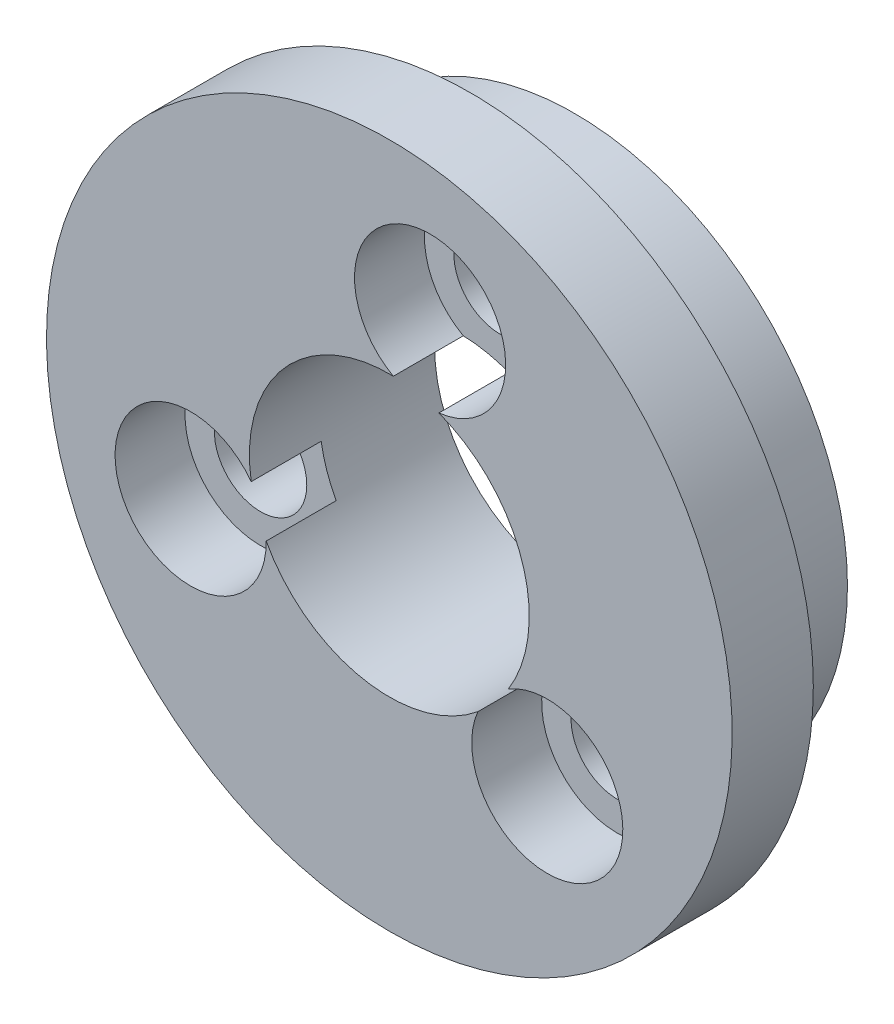
from build123d import *

# Parameters (mm, degrees)
SKETCH1_R           = 12.25
BOSS_EXTRUDE1_DEPTH = 2.9
CUT_EXTRUDE1_REACH  = 364.631
SKETCH2_R           = 5
CUT_EXTRUDE2_REACH  = 364.631
SKETCH5_R           = 1.65
SKETCH6_R           = 9.75
SKETCH6_R_2         = 5
BOSS_EXTRUDE2_DEPTH = 3.72
SKETCH7_R           = 1.65
CUT_EXTRUDE3_DEPTH  = 3.72
SKETCH8_R           = 2.7
CUT_EXTRUDE4_DEPTH  = 2.5


with BuildPart() as part:
    # Sketch1 → Boss-Extrude1 (new body)
    with BuildSketch(Plane.XY):
        with Locations(Location((350.15, -0.367507575, 0), (0, 0, 270))):
            Circle(SKETCH1_R)
    extrude(amount=BOSS_EXTRUDE1_DEPTH)

    # Sketch2 → Cut-Extrude1 (cut, up to next)
    with BuildSketch(Plane.XY.offset(2.9), mode=Mode.PRIVATE) as cut_extrude1_sk1:
        with Locations((350.15, -0.367507575)):
            Circle(SKETCH2_R)
    cut_extrude1_tool1 = extrude(cut_extrude1_sk1.sketch, amount=-CUT_EXTRUDE1_REACH, mode=Mode.PRIVATE) & part.part
    add(cut_extrude1_tool1.solids().sort_by_distance((350.15, -0.367508, 2.9))[0], mode=Mode.SUBTRACT)

    # Sketch5 → Cut-Extrude2 (cut, up to next)
    with BuildSketch(Plane.XY.offset(2.9), mode=Mode.PRIVATE) as cut_extrude2_sk1:
        with Locations((343.05020627, -2.784722708)):
            Circle(SKETCH5_R)
    cut_extrude2_tool1 = extrude(cut_extrude2_sk1.sketch, amount=-CUT_EXTRUDE2_REACH, mode=Mode.PRIVATE) & part.part
    # Sketch5 → Cut-Extrude2 (cut, up to next)
    with BuildSketch(Plane.XY.offset(2.9), mode=Mode.PRIVATE) as cut_extrude2_sk2:
        with Locations((355.793266576, -5.30750174)):
            Circle(SKETCH5_R)
    cut_extrude2_tool2 = extrude(cut_extrude2_sk2.sketch, amount=-CUT_EXTRUDE2_REACH, mode=Mode.PRIVATE) & part.part
    # Sketch5 → Cut-Extrude2 (cut, up to next)
    with BuildSketch(Plane.XY.offset(2.9), mode=Mode.PRIVATE) as cut_extrude2_sk3:
        with Locations((351.606527153, 6.989701723)):
            Circle(SKETCH5_R)
    cut_extrude2_tool3 = extrude(cut_extrude2_sk3.sketch, amount=-CUT_EXTRUDE2_REACH, mode=Mode.PRIVATE) & part.part
    add(cut_extrude2_tool1.solids().sort_by_distance((343.050206, -2.784723, 2.9))[0], mode=Mode.SUBTRACT)
    add(cut_extrude2_tool2.solids().sort_by_distance((355.793267, -5.307502, 2.9))[0], mode=Mode.SUBTRACT)
    add(cut_extrude2_tool3.solids().sort_by_distance((351.606527, 6.989702, 2.9))[0], mode=Mode.SUBTRACT)

    # Sketch6 → Boss-Extrude2 (add)
    with BuildSketch(Plane(origin=(0, 0, 0), x_dir=(-1, 0, 0), z_dir=(0, 0, -1))):
        with Locations(Location((-350.15, -0.367507575, 0), (0, 0, 180))):
            Circle(SKETCH6_R)
        with Locations(Location((-350.15, -0.367507575, 0), (0, 0, 180))):
            Circle(SKETCH6_R_2, mode=Mode.SUBTRACT)
    extrude(amount=BOSS_EXTRUDE2_DEPTH)

    # Sketch7 → Cut-Extrude3 (cut)
    with BuildSketch(Plane.XY):
        with Locations((351.606527153, 6.989701723)):
            Circle(SKETCH7_R)
        with Locations((343.05020627, -2.784722708)):
            Circle(SKETCH7_R)
        with Locations((355.793266576, -5.30750174)):
            Circle(SKETCH7_R)
    extrude(amount=-CUT_EXTRUDE3_DEPTH, mode=Mode.SUBTRACT)

    # Sketch8 → Cut-Extrude4 (cut)
    with BuildSketch(Plane.XY.offset(2.9)):
        with Locations((351.606527153, 6.989701723)):
            Circle(SKETCH8_R)
        with Locations((355.793266576, -5.30750174)):
            Circle(SKETCH8_R)
        with Locations((343.05020627, -2.784722708)):
            Circle(SKETCH8_R)
    extrude(amount=-CUT_EXTRUDE4_DEPTH, mode=Mode.SUBTRACT)


solid = part.part
